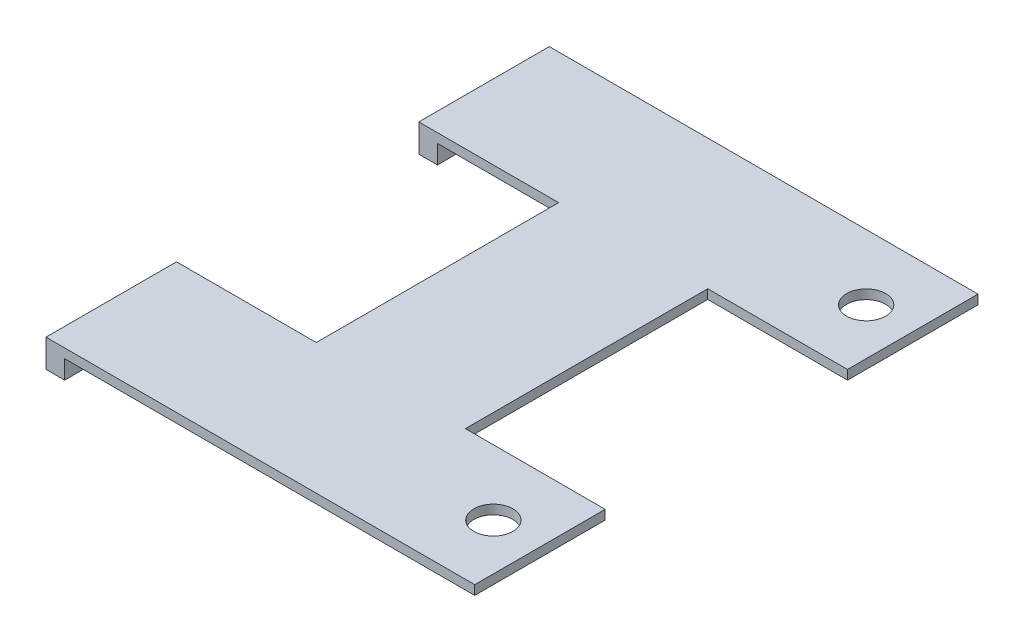
from build123d import *

# Parameters (mm, degrees)
SKETCH1_R           = 2.1
BOSS_EXTRUDE1_DEPTH = 1
SKETCH2_W           = 2
SKETCH2_H           = 14
BOSS_EXTRUDE2_DEPTH = 2


with BuildPart() as part:
    # Sketch1 → Boss-Extrude1 (new body)
    with BuildSketch(Plane(origin=(0, 0, 0), x_dir=(1, 0, 0), z_dir=(0, 1, 0))):
        Polygon((-30.551614771, -125.360414745), (-76.551614771, -125.360414745), (-76.551614771, -139.360414745), (-61.551614771, -139.360414745), (-61.551614771, -165.360414745), (-76.551614771, -165.360414745), (-76.551614771, -179.360414745), (-30.551614771, -179.360414745), (-30.551614771, -165.360414745), (-45.551614771, -165.360414745), (-45.551614771, -139.360414745), (-30.551614771, -139.360414745), align=None)
        with Locations((-35.551614771, -132.360414745)):
            Circle(SKETCH1_R, mode=Mode.SUBTRACT)
        with Locations((-35.551614771, -172.360414745)):
            Circle(SKETCH1_R, mode=Mode.SUBTRACT)
    extrude(amount=BOSS_EXTRUDE1_DEPTH)

    # Sketch2 → Boss-Extrude2 (add)
    with BuildSketch(Plane(origin=(0, 0, 0), x_dir=(-1, 0, 0), z_dir=(0, -1, 0))):
        with Locations((75.551614771, -172.360414745)):
            Rectangle(SKETCH2_W, SKETCH2_H)
        with Locations((75.551614771, -132.360414745)):
            Rectangle(SKETCH2_W, SKETCH2_H)
    extrude(amount=BOSS_EXTRUDE2_DEPTH)


solid = part.part
